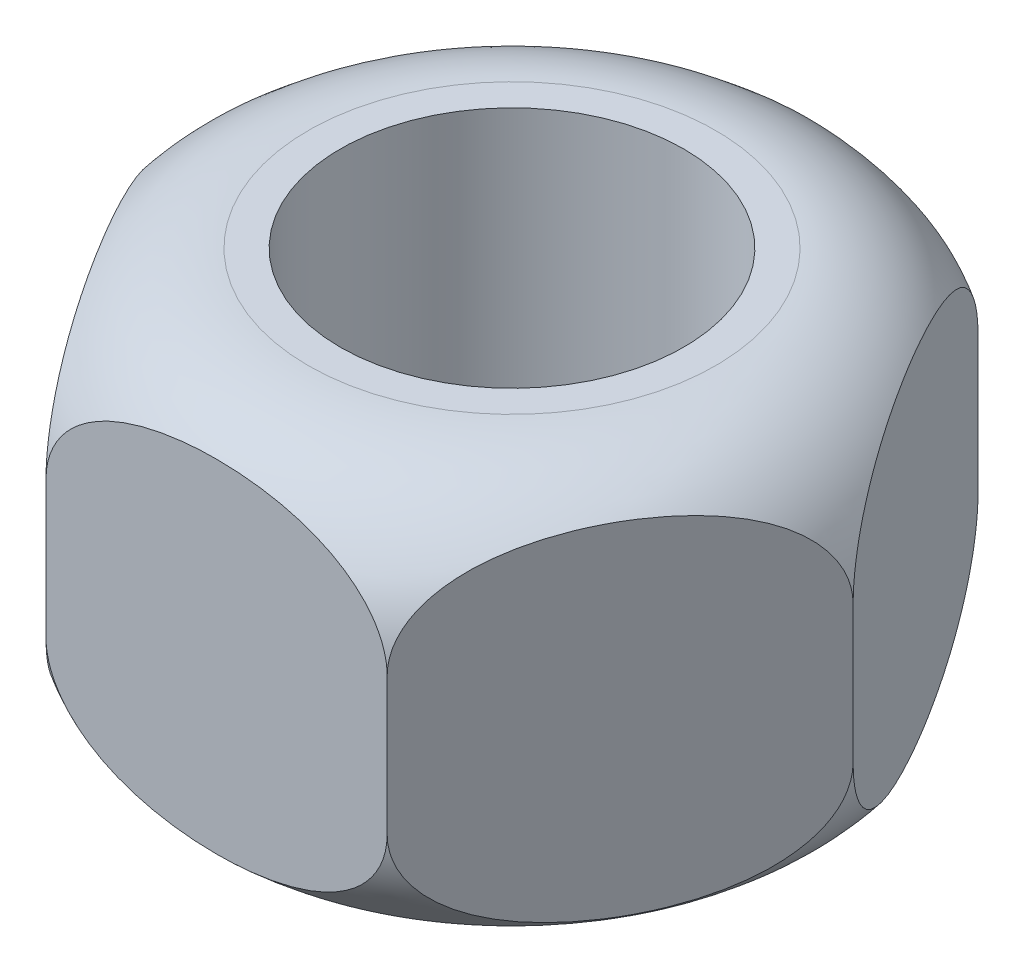
from build123d import *

# Parameters (mm, degrees)
SKETCH2_R           = 1.25
BOSS_EXTRUDE1_DEPTH = 3


with BuildPart() as part:
    # Sketch2 → Boss-Extrude1 (new body)
    with BuildSketch(Plane(origin=(0, 0, 0), x_dir=(1, 0, 0), z_dir=(0, 1, 0))):
        Polygon((2.482606158, 0), (1.241303079, 2.15), (-1.241303079, 2.15), (-2.482606158, 0), (-1.241303079, -2.15), (1.241303079, -2.15), align=None)
        Circle(SKETCH2_R, mode=Mode.SUBTRACT)
    extrude(amount=BOSS_EXTRUDE1_DEPTH)

    # Sketch3 → Cut-Revolve1 (revolve, cut)
    with BuildSketch(Plane.XY):
        with BuildLine():
            Line((2.482606158, 0), (1.482606158, 0))
            ThreePointArc((1.482606158, 0), (2.189712939, 0.292893219), (2.482606158, 1))
            Line((2.482606158, 1), (2.482606158, 0))
        make_face()
        with BuildLine():
            Line((2.482606158, 3), (1.482606158, 3))
            ThreePointArc((1.482606158, 3), (2.189712939, 2.707106781), (2.482606158, 2))
            Line((2.482606158, 2), (2.482606158, 3))
        make_face()
    revolve(axis=Axis((0, 0, 0), (0, -1, 0)), mode=Mode.SUBTRACT)


solid = part.part
